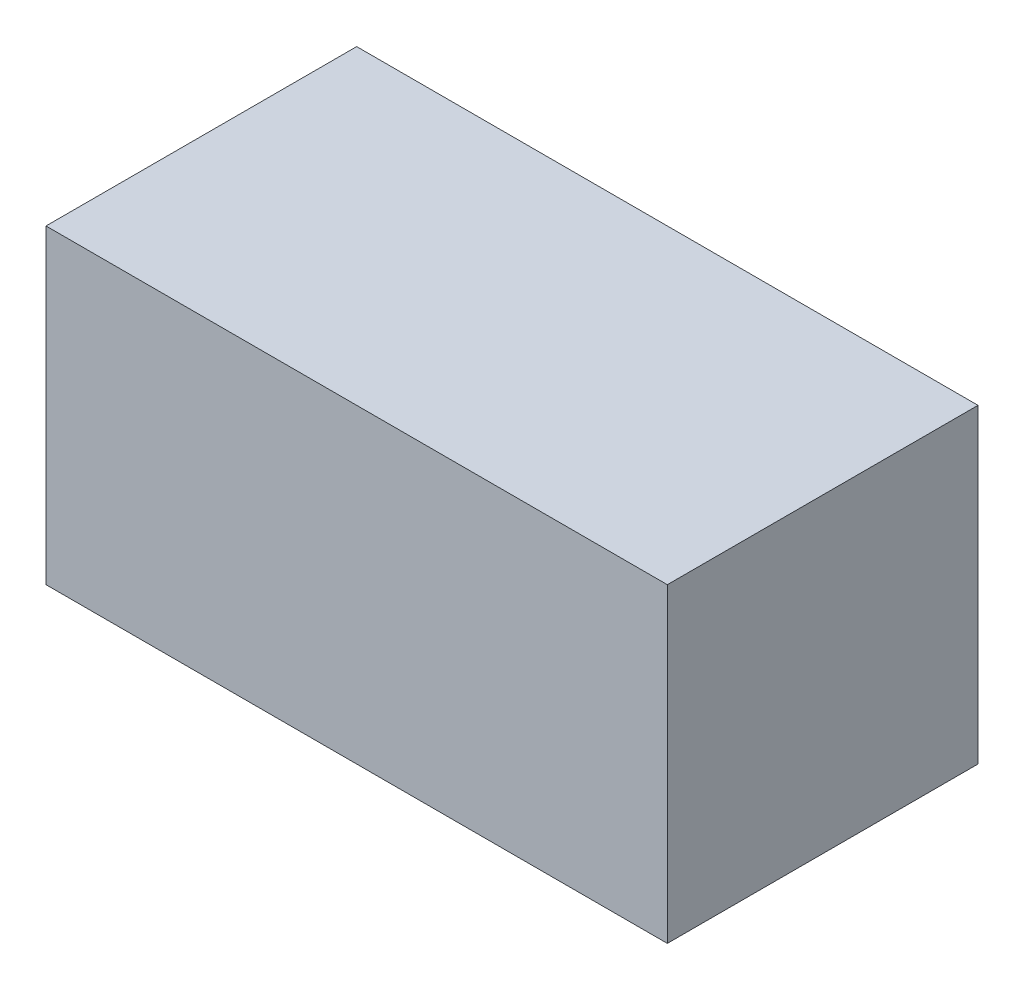
from build123d import *

# Parameters (mm, degrees)
SKETCH1_W           = 100
SKETCH1_H           = 50
BOSS_EXTRUDE1_DEPTH = 50


with BuildPart() as part:
    # Sketch1 → Boss-Extrude1 (new body)
    with BuildSketch(Plane(origin=(0, 0, 0), x_dir=(1, 0, 0), z_dir=(0, 1, 0))):
        Rectangle(SKETCH1_W, SKETCH1_H)
    extrude(amount=BOSS_EXTRUDE1_DEPTH)


solid = part.part
